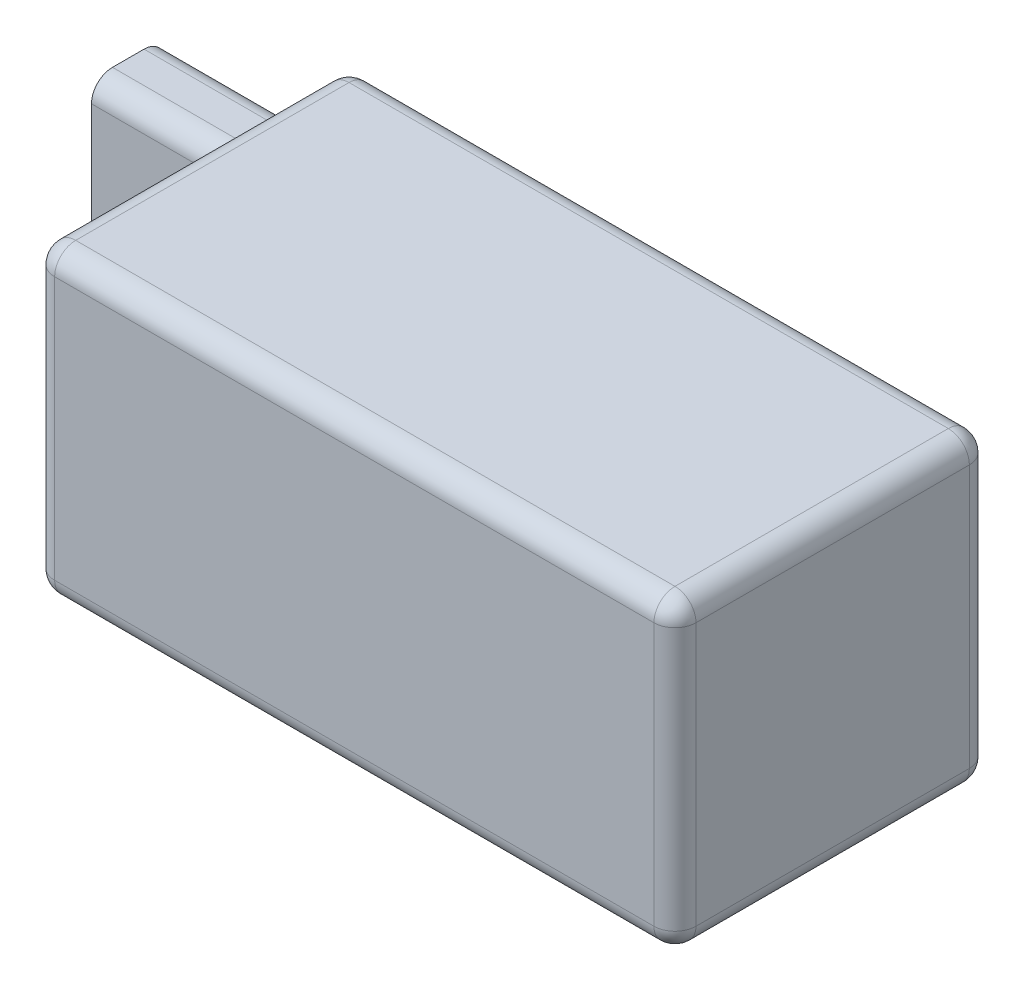
from build123d import *

# Parameters (mm, degrees)
SKETCH1_W           = 61
SKETCH1_H           = 30
BOSS_EXTRUDE1_DEPTH = 29
SKETCH2_W           = 7
SKETCH2_H           = 15
BOSS_EXTRUDE2_DEPTH = 17.5
FILLET1_R           = 2
FILLET2_R           = 2


with BuildPart() as part:
    # Sketch1 → Boss-Extrude1 (new body)
    with BuildSketch(Plane(origin=(0, 0, 0), x_dir=(1, 0, 0), z_dir=(0, 1, 0))):
        Rectangle(SKETCH1_W, SKETCH1_H)
    extrude(amount=BOSS_EXTRUDE1_DEPTH)

    # Sketch2 → Boss-Extrude2 (add)
    with BuildSketch(Plane.ZY.offset(30.5)):
        with Locations((-11.5, 14.5)):
            Rectangle(SKETCH2_W, SKETCH2_H)
    extrude(amount=BOSS_EXTRUDE2_DEPTH)

    # Fillet1
    fillet1_edges = [part.edges().sort_by_distance(p)[0] for p in [
        (-39.25, 22, -15),
        (-39.25, 7, -15),
        (-39.25, 7, -8),
        (-39.25, 22, -8),
    ]]
    fillet(fillet1_edges, radius=FILLET1_R)

    # Fillet2
    fillet2_edges = [part.edges().sort_by_distance(p)[0] for p in [
        (30.5, 14.5, -15),
        (0, 29, -15),
        (30.5, 29, 0),
        (-30.5, 29, 0),
        (30.5, 0, 0),
        (0, 0, -15),
        (-30.5, 0, 0),
        (-30.5, 14.5, 15),
        (0, 29, 15),
        (30.5, 14.5, 15),
        (0, 0, 15),
        (-30.5, 25.5, -15),
        (-30.5, 3.5, -15),
    ]]
    fillet(fillet2_edges, radius=FILLET2_R)


solid = part.part
